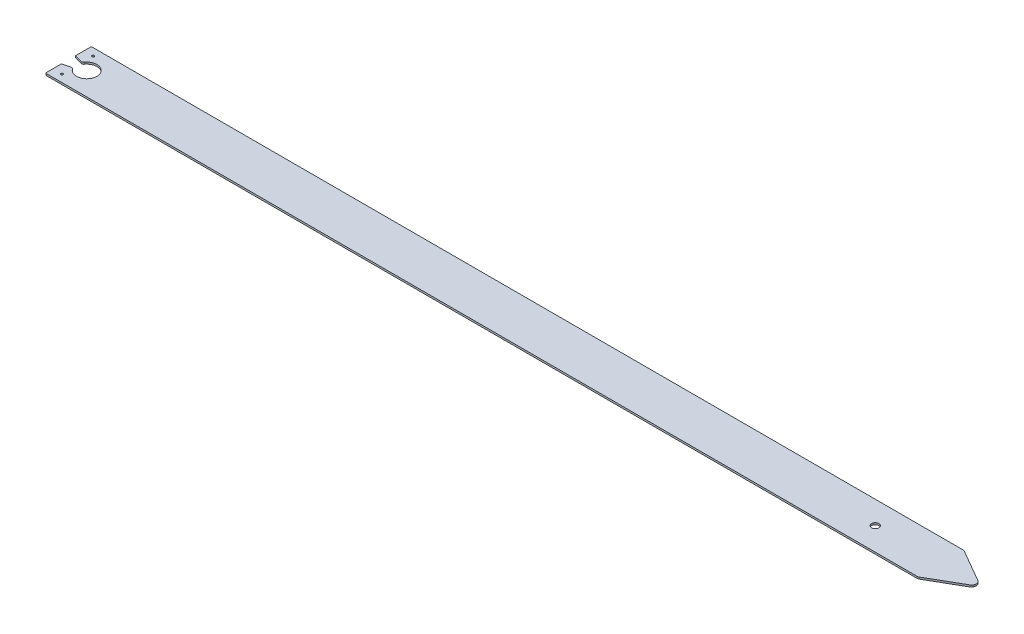
from build123d import *

# Parameters (mm, degrees)
SKETCH1_R           = 4
SKETCH1_R_2         = 1.25
BOSS_EXTRUDE1_DEPTH = 2
FILLET1_R           = 1
CUT_EXTRUDE1_DEPTH  = 2


with BuildPart() as part:
    # Sketch1 → Boss-Extrude1 (new body)
    with BuildSketch(Plane(origin=(0, 0, 0), x_dir=(1, 0, 0), z_dir=(0, 1, 0))):
        with BuildLine():
            Line((987.5, 29.330127019), (952.858983849, 49.330127019))
            ThreePointArc((952.858983849, 49.330127019), (951.653079074, 49.829629131), (950.358983849, 50))
            Line((950.358983849, 50), (0, 50))
            Line((0, 50), (0, 0))
            Line((0, 0), (950.358983849, 0))
            ThreePointArc((950.358983849, 0), (951.653079074, 0.170370869), (952.858983849, 0.669872981))
            Line((952.858983849, 0.669872981), (987.5, 20.669872981))
            ThreePointArc((987.5, 20.669872981), (990, 25), (987.5, 29.330127019))
        make_face()
        with Locations((880, 25)):
            Circle(SKETCH1_R, mode=Mode.SUBTRACT)
        with Locations((10, 42)):
            Circle(SKETCH1_R_2, mode=Mode.SUBTRACT)
        with Locations((10, 8)):
            Circle(SKETCH1_R_2, mode=Mode.SUBTRACT)
    extrude(amount=BOSS_EXTRUDE1_DEPTH)

    # Fillet1
    fillet1_edges = [part.edges().sort_by_distance(p)[0] for p in [
        (0, 1, -50),
        (0, 1, 0),
    ]]
    fillet(fillet1_edges, radius=FILLET1_R)

    # Sketch2 → Cut-Extrude1 (cut)
    with BuildSketch(Plane(origin=(0, 2, 0), x_dir=(1, 0, 0), z_dir=(0, 1, 0))):
        with BuildLine():
            Line((8.184981615, 19.51366729), (0, 17.320508076))
            Line((0, 17.320508076), (0, 32.679491924))
            Line((0, 32.679491924), (8.184981615, 30.48633271))
            ThreePointArc((8.184981615, 30.48633271), (9.68136243, 30.549842721), (10.872908853, 31.457260037))
            ThreePointArc((10.872908853, 31.457260037), (31.180339887, 25), (10.872908853, 18.542739963))
            ThreePointArc((10.872908853, 18.542739963), (9.68136243, 19.450157279), (8.184981615, 19.51366729))
        make_face()
    extrude(amount=-CUT_EXTRUDE1_DEPTH, mode=Mode.SUBTRACT)


solid = part.part
